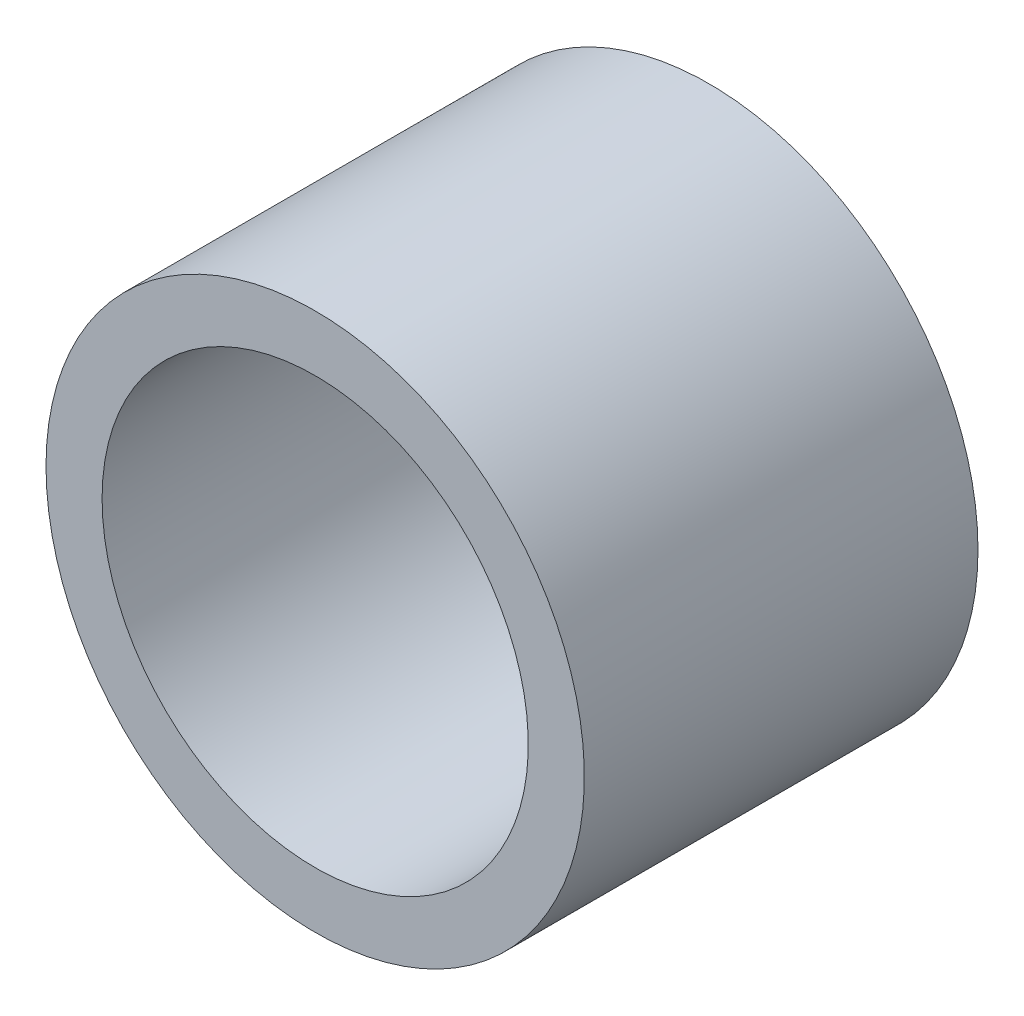
from build123d import *

# Parameters (mm, degrees)
CROQUIS1_R              = 12
CROQUIS1_R_2            = 9.5
SALIENTE_EXTRUIR1_DEPTH = 17.548603


with BuildPart() as part:
    # Croquis1 → Saliente-Extruir1 (new body)
    with BuildSketch(Plane.XY):
        with Locations((24.835128068, -26)):
            Circle(CROQUIS1_R)
        with Locations((24.835128068, -26)):
            Circle(CROQUIS1_R_2, mode=Mode.SUBTRACT)
    extrude(amount=SALIENTE_EXTRUIR1_DEPTH)


solid = part.part
